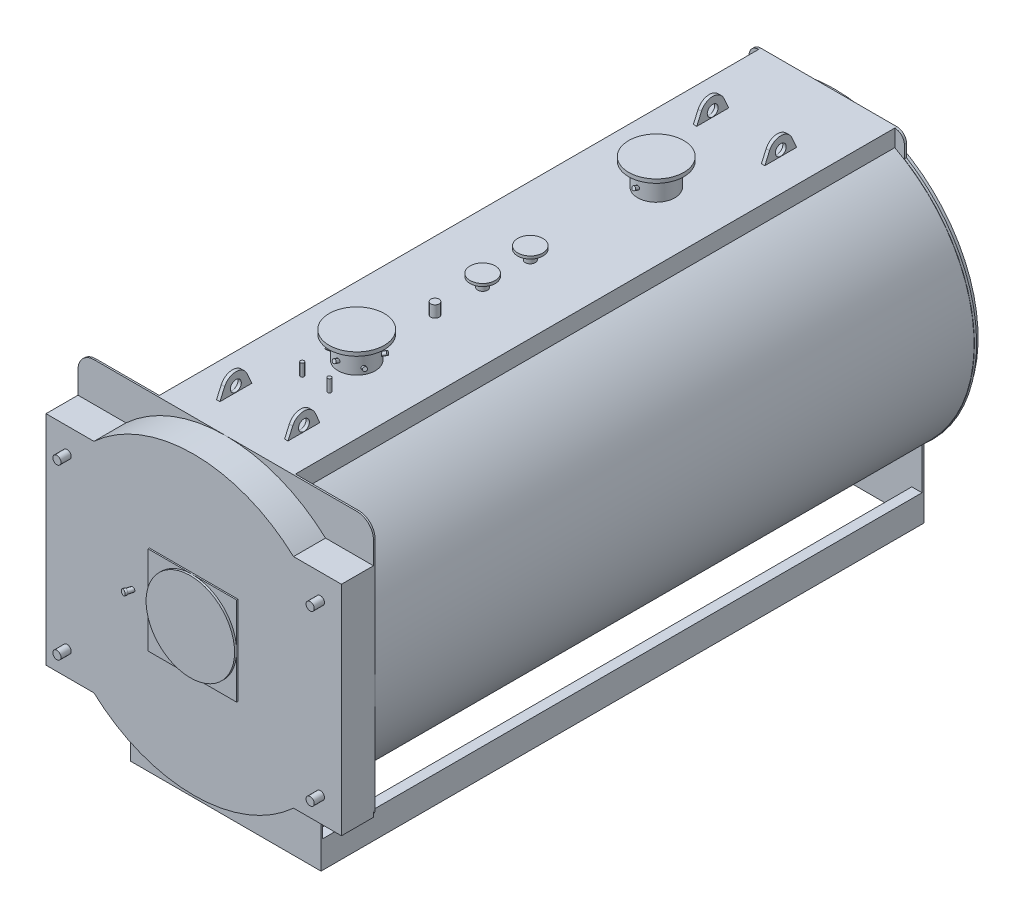
from build123d import *

# Parameters (mm, degrees)
PIASTRA_ANTERIORE_DEPTH       = 12
CORPO_DEPTH                   = 4402
PIASTRA_POSTERIORE_DEPTH      = 16
BASAMENTO_DEPTH               = 4402
ESTRUSIONE_ESTRUSIONE3_DEPTH  = 235
SCHIZZO8_W                    = 650
SCHIZZO8_H                    = 650
ESTRUSIONE_ESTRUSIONE4_DEPTH  = 10
SCHIZZO9_R                    = 325
ESTRUSIONE_ESTRUSIONE5_DEPTH  = 15
SCHIZZO12_R                   = 30
ESTRUSIONE_ESTRUSIONE6_DEPTH  = 75
SCHIZZO13_R                   = 136.5
ESTRUSIONE_ESTRUSIONE7_DEPTH  = 1280
SCHIZZO14_R                   = 202.5
ESTRUSIONE_ESTRUSIONE8_DEPTH  = 28
SCHIZZO13_3_R                 = 36.5
ESTRUSIONE_ESTRUSIONE9_DEPTH  = 1175
SCHIZZO15_R                   = 92.5
ESTRUSIONE_ESTRUSIONE10_DEPTH = 20
SCHIZZO13_4_R                 = 30.15
ESTRUSIONE_ESTRUSIONE11_DEPTH = 1170
SCHIZZO13_5_R                 = 13.35
ESTRUSIONE_ESTRUSIONE12_DEPTH = 1175
RIPETIZIONECIRCOLARE1_COUNT   = 3
SCHIZZO21_R                   = 24.15
ESTRUSIONE_ESTRUSIONE13_DEPTH = 149
SCHIZZO21_3_R                 = 24.15
ESTRUSIONE_ESTRUSIONE14_DEPTH = 50
SCHIZZO22_R                   = 75
ESTRUSIONE_ESTRUSIONE15_DEPTH = 16
GOLFARE_START                 = 250
SCHIZZO23_R                   = 40
GOLFARE_DEPTH                 = 12.5


with BuildPart() as part:
    # Schizzo1 → piastra anteriore (new body)
    with BuildSketch(Plane.XY):
        with BuildLine():
            Line((-965, 2420), (965, 2420))
            ThreePointArc((965, 2420), (1049.852813742, 2384.852813742), (1085, 2300))
            Line((1085, 2300), (1085, 575))
            ThreePointArc((1085, 575), (1073.284271247, 546.715728753), (1045, 535))
            Line((1045, 535), (700, 535))
            Line((700, 535), (700, 0))
            Line((700, 0), (-700, 0))
            Line((-700, 0), (-700, 535))
            Line((-700, 535), (-1045, 535))
            ThreePointArc((-1045, 535), (-1073.284271247, 546.715728753), (-1085, 575))
            Line((-1085, 575), (-1085, 2300))
            ThreePointArc((-1085, 2300), (-1049.852813742, 2384.852813742), (-965, 2420))
        make_face()
    extrude(amount=-PIASTRA_ANTERIORE_DEPTH)

    # Schizzo2 → corpo (add)
    with BuildSketch(Plane(origin=(0, 0, -12), x_dir=(-1, 0, 0), z_dir=(0, 0, -1))):
        with BuildLine():
            Line((500, 2295.107415866), (500, 2420))
            Line((500, 2420), (-500, 2420))
            Line((-500, 2420), (-500, 2295.107415866))
            ThreePointArc((-500, 2295.107415866), (0, 252.5), (500, 2295.107415866))
        make_face()
        with BuildLine():
            Line((490, 2289.021095155), (490, 2410))
            Line((490, 2410), (-490, 2410))
            Line((-490, 2410), (-490, 2289.021095155))
            ThreePointArc((-490, 2289.021095155), (0, 262.5), (490, 2289.021095155))
        make_face(mode=Mode.SUBTRACT)
    extrude(amount=CORPO_DEPTH)

    # Schizzo3 → piastra posteriore (add)
    with BuildSketch(Plane(origin=(0, 0, -4414), x_dir=(-1, 0, 0), z_dir=(0, 0, -1))):
        with BuildLine():
            Line((-570, 2258.214492954), (-570, 2350))
            ThreePointArc((-570, 2350), (-549.497474683, 2399.497474683), (-500, 2420))
            Line((-500, 2420), (500, 2420))
            ThreePointArc((500, 2420), (549.497474683, 2399.497474683), (570, 2350))
            Line((570, 2350), (570, 2258.214492954))
            ThreePointArc((570, 2258.214492954), (1082.02608689, 1415.277937754), (700, 506.009650237))
            Line((700, 506.009650237), (700, 0))
            Line((700, 0), (-700, 0))
            Line((-700, 0), (-700, 506.009650237))
            ThreePointArc((-700, 506.009650237), (-1082.02608689, 1415.277937754), (-570, 2258.214492954))
        make_face()
    extrude(amount=PIASTRA_POSTERIORE_DEPTH)

    # Schizzo5 → camera fumo (revolve)
    with BuildSketch(Plane(origin=(0, 0, 0), x_dir=(0, 0, -1), z_dir=(1, 0, 0)), mode=Mode.PRIVATE) as camera_fumo_sk:
        Polygon((4471, 1634), (4574, 1634), (4574, 1675), (4579, 1675), (4579, 1629), (4471, 1629), (4471, 1335), (4430, 1335), (4430, 2390), (4471, 2390), align=None)
    revolve(camera_fumo_sk.sketch.rotate(Axis((0, 1335, -4414), (0, 0, -1)), 90), axis=Axis((0, 1335, -4414), (0, 0, -1)))  # turned: the seam where the file's is

    # Schizzo6 → basamento (add)
    with BuildSketch(Plane(origin=(0, 0, -12), x_dir=(-1, 0, 0), z_dir=(0, 0, -1))):
        Polygon((-625, 0), (-700, 0), (-700, 200), (-625, 200), (-625, 190), (-690, 190), (-690, 10), (-625, 10), align=None)
    basamento = extrude(amount=BASAMENTO_DEPTH)

    # Specchia2: basamento across plane
    add(basamento.mirror(Plane(origin=(0, 0, 0), x_dir=(0, 0, 1), z_dir=(1, 0, 0))))

    # Schizzo7 → Estrusione-Estrusione3 (add)
    with BuildSketch(Plane.XY):
        with BuildLine():
            Line((732.956342493, 2135), (1085, 2135))
            Line((1085, 2135), (1085, 535))
            Line((1085, 535), (732.956342493, 535))
            ThreePointArc((732.956342493, 535), (0, 250), (-732.956342493, 535))
            Line((-732.956342493, 535), (-1085, 535))
            Line((-1085, 535), (-1085, 2135))
            Line((-1085, 2135), (-732.956342493, 2135))
            ThreePointArc((-732.956342493, 2135), (0, 2420), (732.956342493, 2135))
        make_face()
    extrude(amount=ESTRUSIONE_ESTRUSIONE3_DEPTH)

    # Schizzo8 → Estrusione-Estrusione4 (add)
    with BuildSketch(Plane.XY.offset(235)):
        with Locations((0, 1335)):
            Rectangle(SCHIZZO8_W, SCHIZZO8_H)
    extrude(amount=ESTRUSIONE_ESTRUSIONE4_DEPTH)

    # Schizzo9 → Estrusione-Estrusione5 (add)
    with BuildSketch(Plane.XY.offset(245)):
        with Locations((0, 1335)):
            Circle(SCHIZZO9_R)
    extrude(amount=ESTRUSIONE_ESTRUSIONE5_DEPTH)

    # Schizzo11 → Rivoluzione2 (revolve)
    with BuildSketch(Plane(origin=(0, 1335, 0), x_dir=(1, 0, 0), z_dir=(0, 1, 0)), mode=Mode.PRIVATE) as rivoluzione2_sk:
        Polygon((-464.268693957, -288.251490803), (-446.162357162, -220.677721947), (-430.031395863, -225), (-443.996627936, -277.118955636), (-440.809072709, -277.973058485), (-444.950177431, -293.427871705), align=None)
    revolve(rivoluzione2_sk.sketch.rotate(Axis((-450, 1335, 235), (-0.258819045, 0, 0.965925826)), 180), axis=Axis((-450, 1335, 235), (-0.258819045, 0, 0.965925826)))  # turned: the seam where the file's is

    # Schizzo12 → Estrusione-Estrusione6 (add)
    with BuildSketch(Plane.XY.offset(235)):
        with Locations((-930, 1955)):
            Circle(SCHIZZO12_R)
        with Locations(Location((930, 1955, 0), (0, 0, 180))):  # turned: the seam where the file's is
            Circle(SCHIZZO12_R)
        with Locations((930, 715)):
            Circle(SCHIZZO12_R)
        with Locations(Location((-930, 715, 0), (0, 0, 180))):  # turned: the seam where the file's is
            Circle(SCHIZZO12_R)
    extrude(amount=ESTRUSIONE_ESTRUSIONE6_DEPTH)

    # Schizzo13 → Estrusione-Estrusione7 (add)
    with BuildSketch(Plane(origin=(0, 1335, 0), x_dir=(1, 0, 0), z_dir=(0, 1, 0))):
        with Locations(Location((0, 962, 0), (0, 0, 90))):  # turned: the seam where the file's is
            Circle(SCHIZZO13_R)
        with Locations(Location((0, 3162, 0), (0, 0, 90))):  # turned: the seam where the file's is
            Circle(SCHIZZO13_R)
    extrude(amount=ESTRUSIONE_ESTRUSIONE7_DEPTH)

    # Schizzo14 → Estrusione-Estrusione8 (add)
    with BuildSketch(Plane(origin=(0, 2615, 0), x_dir=(1, 0, 0), z_dir=(0, 1, 0))):
        with Locations(Location((0, 962, 0), (0, 0, 270))):  # turned: the seam where the file's is
            Circle(SCHIZZO14_R)
        with Locations(Location((0, 3162, 0), (0, 0, 270))):  # turned: the seam where the file's is
            Circle(SCHIZZO14_R)
    extrude(amount=-ESTRUSIONE_ESTRUSIONE8_DEPTH)

    # Schizzo13_3 → Estrusione-Estrusione9 (add)
    with BuildSketch(Plane(origin=(0, 1335, 0), x_dir=(1, 0, 0), z_dir=(0, 1, 0))):
        with Locations(Location((0, 2237, 0), (0, 0, 90))):  # turned: the seam where the file's is
            Circle(SCHIZZO13_3_R)
        with Locations(Location((0, 1887, 0), (0, 0, 90))):  # turned: the seam where the file's is
            Circle(SCHIZZO13_3_R)
    extrude(amount=ESTRUSIONE_ESTRUSIONE9_DEPTH)

    # Schizzo15 → Estrusione-Estrusione10 (add)
    with BuildSketch(Plane(origin=(0, 2510, 0), x_dir=(1, 0, 0), z_dir=(0, 1, 0))):
        with Locations(Location((0, 2237, 0), (0, 0, 270))):  # turned: the seam where the file's is
            Circle(SCHIZZO15_R)
        with Locations(Location((0, 1887, 0), (0, 0, 270))):  # turned: the seam where the file's is
            Circle(SCHIZZO15_R)
    extrude(amount=-ESTRUSIONE_ESTRUSIONE10_DEPTH)

    # Schizzo13_4 → Estrusione-Estrusione11 (add)
    with BuildSketch(Plane(origin=(0, 1335, 0), x_dir=(1, 0, 0), z_dir=(0, 1, 0))):
        with Locations(Location((0, 1537, 0), (0, 0, 90))):  # turned: the seam where the file's is
            Circle(SCHIZZO13_4_R)
    extrude(amount=ESTRUSIONE_ESTRUSIONE11_DEPTH)

    # Schizzo13_5 → Estrusione-Estrusione12 (add)
    with BuildSketch(Plane(origin=(0, 1335, 0), x_dir=(1, 0, 0), z_dir=(0, 1, 0))):
        with Locations(Location((-100, 662, 0), (0, 0, 90))):  # turned: the seam where the file's is
            Circle(SCHIZZO13_5_R)
        with Locations(Location((100, 662, 0), (0, 0, 90))):  # turned: the seam where the file's is
            Circle(SCHIZZO13_5_R)
    extrude(amount=ESTRUSIONE_ESTRUSIONE12_DEPTH)

    # Schizzo16 → Rivoluzione3 (revolve)
    with BuildSketch(Plane(origin=(0, 0, 0), x_dir=(0, 0, -1), z_dir=(1, 0, 0))):
        Polygon((2996.199829072, 2495.664390077), (3000.8, 2508.303255826), (3047.784631039, 2491.20224866), (3043.184460112, 2478.56338291), align=None)
    revolve(axis=Axis((0, 2485, -3025.5), (0, 0.342020143, 0.939692621)))

    # Schizzo17 → Rivoluzione4 (revolve)
    with BuildSketch(Plane(origin=(0, 0, 0), x_dir=(0, 0, -1), z_dir=(1, 0, 0))):
        Polygon((796.199829072, 2495.664390077), (800.8, 2508.303255826), (847.784631039, 2491.20224866), (843.184460112, 2478.56338291), align=None)
    rivoluzione4 = revolve(axis=Axis((0, 2485, -825.5), (0, 0.342020143, 0.939692621)))

    # Schizzo18 → Rivoluzione5 (revolve)
    with BuildSketch(Plane(origin=(0, 0, 0), x_dir=(0, 0, -1), z_dir=(1, 0, 0))):
        Polygon((1127.800170928, 2475.664390077), (1123.2, 2488.303255826), (1076.215368961, 2471.20224866), (1080.815539888, 2458.56338291), align=None)
    rivoluzione5 = revolve(axis=Axis((0, 2465, -1098.5), (0, -0.342020143, 0.939692621)))

    # RipetizioneCircolare1: Rivoluzione4, Rivoluzione5 ×3 about axis
    ripetizionecircolare1_axis = Axis((0, 0, -962), (0, 1, 0))
    add([rivoluzione4.rotate(ripetizionecircolare1_axis, i * 360 / RIPETIZIONECIRCOLARE1_COUNT) for i in range(1, RIPETIZIONECIRCOLARE1_COUNT)])
    add([rivoluzione5.rotate(ripetizionecircolare1_axis, i * 360 / RIPETIZIONECIRCOLARE1_COUNT) for i in range(1, RIPETIZIONECIRCOLARE1_COUNT)])

    # Schizzo21 → Estrusione-Estrusione13 (add)
    with BuildSketch(Plane(origin=(0, 0, -4430), x_dir=(-1, 0, 0), z_dir=(0, 0, -1))):
        with Locations((0, 125)):
            Circle(SCHIZZO21_R)
    extrude(amount=ESTRUSIONE_ESTRUSIONE13_DEPTH)

    # Schizzo21_3 → Estrusione-Estrusione14 (add)
    with BuildSketch(Plane(origin=(0, 0, -4430), x_dir=(-1, 0, 0), z_dir=(0, 0, -1))):
        with Locations(Location((0, 260, 0), (0, 0, 123.727665246))):  # turned: the seam where the file's is
            Circle(SCHIZZO21_3_R)
    extrude(amount=ESTRUSIONE_ESTRUSIONE14_DEPTH)

    # Schizzo22 → Estrusione-Estrusione15 (add)
    with BuildSketch(Plane(origin=(0, 0, -4579), x_dir=(-1, 0, 0), z_dir=(0, 0, -1))):
        with Locations((0, 125)):
            Circle(SCHIZZO22_R)
    extrude(amount=-ESTRUSIONE_ESTRUSIONE15_DEPTH)

    # Schizzo23 → golfare (add, symmetric)
    with BuildSketch(Plane(origin=(0, 0, 0), x_dir=(0, 0, -1), z_dir=(1, 0, 0)).offset(GOLFARE_START)):
        with BuildLine():
            Line((187, 2322), (187, 2402))
            Line((187, 2402), (229.707899924, 2498.441875159))
            ThreePointArc((229.707899924, 2498.441875159), (312, 2552), (394.292100076, 2498.441875159))
            Line((394.292100076, 2498.441875159), (437, 2402))
            Line((437, 2402), (437, 2322))
            Line((437, 2322), (187, 2322))
        make_face()
        with Locations((312, 2462)):
            Circle(SCHIZZO23_R, mode=Mode.SUBTRACT)
        with BuildLine():
            Line((3689, 2322), (3689, 2402))
            Line((3689, 2402), (3731.707899924, 2498.441875159))
            ThreePointArc((3731.707899924, 2498.441875159), (3814, 2552), (3896.292100076, 2498.441875159))
            Line((3896.292100076, 2498.441875159), (3939, 2402))
            Line((3939, 2402), (3939, 2322))
            Line((3939, 2322), (3689, 2322))
        make_face()
        with Locations((3814, 2462)):
            Circle(SCHIZZO23_R, mode=Mode.SUBTRACT)
    golfare = extrude(amount=GOLFARE_DEPTH, both=True)

    # Specchia3: golfare across plane
    add(golfare.mirror(Plane(origin=(0, 0, 0), x_dir=(0, 0, 1), z_dir=(1, 0, 0))))


solid = part.part
